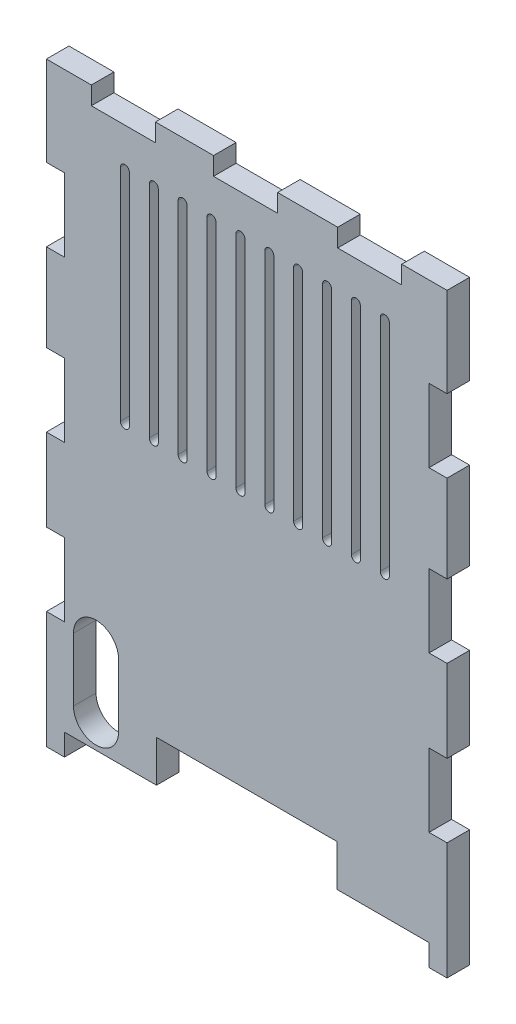
from build123d import *

# Parameters (mm, degrees)
RESSALTO_EXTRUS_O1_DEPTH = 2.5


with BuildPart() as part:
    # Esboço1 → Ressalto-extrusão1 (new body)
    with BuildSketch(Plane.XY):
        Polygon((-25.098396903, -50.388461043), (-23.098396903, -50.388461043), (-23.098396903, -47.988461043), (-12.898396903, -47.988461043), (-12.898396903, -43.388461043), (7.101603097, -43.388461043), (7.101603097, -47.988461043), (17.301603097, -47.988461043), (17.301603097, -50.388461043), (19.301603097, -50.388461043), (19.301603097, -37.412155135), (17.301603097, -37.412155135), (17.301603097, -29.312155135), (19.301603097, -29.312155135), (19.301603097, -20.19154649), (17.301603097, -20.19154649), (17.301603097, -12.09154649), (19.301603097, -12.09154649), (19.301603097, -2.411827174), (17.301603097, -2.411827174), (17.301603097, 5.688172826), (19.301603097, 5.688172826), (19.301603097, 15.611538957), (14.281603097, 15.611538957), (14.281603097, 13.615257293), (7.181603097, 13.615257293), (7.181603097, 15.611538957), (0.521603097, 15.611538957), (0.521603097, 13.615257293), (-6.578396903, 13.615257293), (-6.578396903, 15.611538957), (-13.018396903, 15.611538957), (-13.018396903, 13.615257293), (-20.118396903, 13.615257293), (-20.118396903, 15.611538957), (-25.098396903, 15.611538957), (-25.098396903, 5.691538957), (-23.098396903, 5.691538957), (-23.098396903, -2.408461043), (-25.098396903, -2.408461043), (-25.098396903, -12.088461043), (-23.098396903, -12.088461043), (-23.098396903, -20.188461043), (-25.098396903, -20.188461043), (-25.098396903, -29.308461043), (-23.098396903, -29.308461043), (-23.098396903, -37.408461043), (-25.098396903, -37.408461043), align=None)
        with BuildLine():
            ThreePointArc((-22.098396903, -37.988461043), (-19.598396903, -35.488461043), (-17.098396903, -37.988461043))
            Line((-17.098396903, -37.988461043), (-17.098396903, -44.988461043))
            ThreePointArc((-17.098396903, -44.988461043), (-19.598396903, -47.488461043), (-22.098396903, -44.988461043))
            Line((-22.098396903, -44.988461043), (-22.098396903, -37.988461043))
        make_face(mode=Mode.SUBTRACT)
        with BuildLine():
            ThreePointArc((-16.898396903, 9.334849068), (-16.398396903, 9.834849068), (-15.898396903, 9.334849068))
            Line((-15.898396903, 9.334849068), (-15.898396903, -15.047771388))
            ThreePointArc((-15.898396903, -15.047771388), (-16.398396903, -15.547771388), (-16.898396903, -15.047771388))
            Line((-16.898396903, -15.047771388), (-16.898396903, 9.334849068))
        make_face(mode=Mode.SUBTRACT)
        with BuildLine():
            ThreePointArc((-13.698396903, 9.334849068), (-13.198396903, 9.834849068), (-12.698396903, 9.334849068))
            Line((-12.698396903, 9.334849068), (-12.698396903, -15.047771388))
            ThreePointArc((-12.698396903, -15.047771388), (-13.198396903, -15.547771388), (-13.698396903, -15.047771388))
            Line((-13.698396903, -15.047771388), (-13.698396903, 9.334849068))
        make_face(mode=Mode.SUBTRACT)
        with BuildLine():
            ThreePointArc((-10.498396903, 9.334849068), (-9.998396903, 9.834849068), (-9.498396903, 9.334849068))
            Line((-9.498396903, 9.334849068), (-9.498396903, -15.047771388))
            ThreePointArc((-9.498396903, -15.047771388), (-9.998396903, -15.547771388), (-10.498396903, -15.047771388))
            Line((-10.498396903, -15.047771388), (-10.498396903, 9.334849068))
        make_face(mode=Mode.SUBTRACT)
        with BuildLine():
            ThreePointArc((-7.298396903, 9.334849068), (-6.798396903, 9.834849068), (-6.298396903, 9.334849068))
            Line((-6.298396903, 9.334849068), (-6.298396903, -15.047771388))
            ThreePointArc((-6.298396903, -15.047771388), (-6.798396903, -15.547771388), (-7.298396903, -15.047771388))
            Line((-7.298396903, -15.047771388), (-7.298396903, 9.334849068))
        make_face(mode=Mode.SUBTRACT)
        with BuildLine():
            ThreePointArc((-4.098396903, 9.334849068), (-3.598396903, 9.834849068), (-3.098396903, 9.334849068))
            Line((-3.098396903, 9.334849068), (-3.098396903, -15.047771388))
            ThreePointArc((-3.098396903, -15.047771388), (-3.598396903, -15.547771388), (-4.098396903, -15.047771388))
            Line((-4.098396903, -15.047771388), (-4.098396903, 9.334849068))
        make_face(mode=Mode.SUBTRACT)
        with BuildLine():
            ThreePointArc((-0.898396903, 9.334849068), (-0.398396903, 9.834849068), (0.101603097, 9.334849068))
            Line((0.101603097, 9.334849068), (0.101603097, -15.047771388))
            ThreePointArc((0.101603097, -15.047771388), (-0.398396903, -15.547771388), (-0.898396903, -15.047771388))
            Line((-0.898396903, -15.047771388), (-0.898396903, 9.334849068))
        make_face(mode=Mode.SUBTRACT)
        with BuildLine():
            ThreePointArc((2.301603097, 9.334849068), (2.801603097, 9.834849068), (3.301603097, 9.334849068))
            Line((3.301603097, 9.334849068), (3.301603097, -15.047771388))
            ThreePointArc((3.301603097, -15.047771388), (2.801603097, -15.547771388), (2.301603097, -15.047771388))
            Line((2.301603097, -15.047771388), (2.301603097, 9.334849068))
        make_face(mode=Mode.SUBTRACT)
        with BuildLine():
            ThreePointArc((5.501603097, 9.334849068), (6.001603097, 9.834849068), (6.501603097, 9.334849068))
            Line((6.501603097, 9.334849068), (6.501603097, -15.047771388))
            ThreePointArc((6.501603097, -15.047771388), (6.001603097, -15.547771388), (5.501603097, -15.047771388))
            Line((5.501603097, -15.047771388), (5.501603097, 9.334849068))
        make_face(mode=Mode.SUBTRACT)
        with BuildLine():
            ThreePointArc((8.701603097, 9.334849068), (9.201603097, 9.834849068), (9.701603097, 9.334849068))
            Line((9.701603097, 9.334849068), (9.701603097, -15.047771388))
            ThreePointArc((9.701603097, -15.047771388), (9.201603097, -15.547771388), (8.701603097, -15.047771388))
            Line((8.701603097, -15.047771388), (8.701603097, 9.334849068))
        make_face(mode=Mode.SUBTRACT)
        with BuildLine():
            ThreePointArc((11.901603097, 9.334849068), (12.401603097, 9.834849068), (12.901603097, 9.334849068))
            Line((12.901603097, 9.334849068), (12.901603097, -15.047771388))
            ThreePointArc((12.901603097, -15.047771388), (12.401603097, -15.547771388), (11.901603097, -15.047771388))
            Line((11.901603097, -15.047771388), (11.901603097, 9.334849068))
        make_face(mode=Mode.SUBTRACT)
    extrude(amount=RESSALTO_EXTRUS_O1_DEPTH)


solid = part.part
